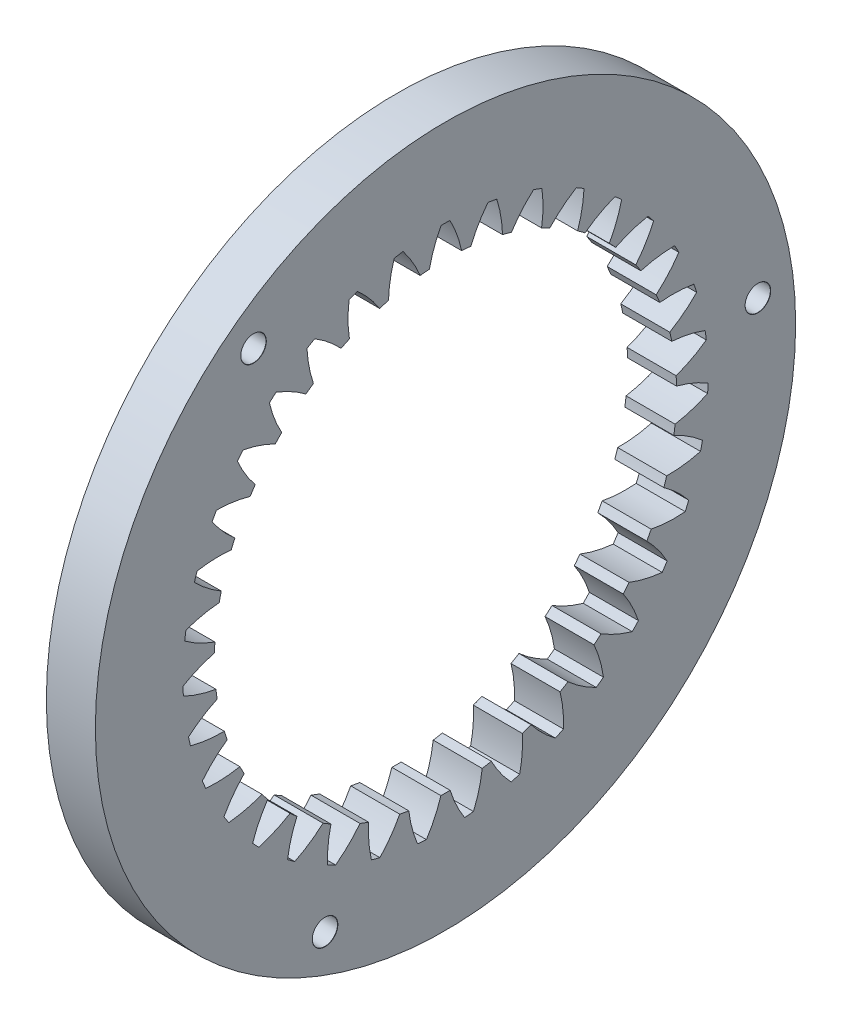
from build123d import *

# Parameters (mm, degrees)
SKETCH1_R                                    = 50
BOSS_EXTRUDE1_DEPTH                          = 7
CSK_FOR_M3_COUNTERSUNK_FLAT_HEAD_SCR_2_COUNT = 2
CSK_FOR_M3_COUNTERSUNK_FLAT_HEAD_SCR_2_PITCH = 77.942286341
CSK_FOR_M3_COUNTERSUNK_FLAT_HEAD_SCR_3_COUNT = 2
CSK_FOR_M3_COUNTERSUNK_FLAT_HEAD_SCR_3_PITCH = 77.942286341


with BuildPart() as part:
    # Sketch1 → Boss-Extrude1 (new body)
    with BuildSketch(Plane(origin=(-42.581895679, 0, 0), x_dir=(0, 0, -1), z_dir=(1, 0, 0))):
        with Locations((-27.777083352, -7.035052717)):
            Circle(SKETCH1_R)
        with BuildLine():
            ThreePointArc((-24.162682124, 25.766412247), (-23.082664784, 27.954818283), (-21.708715074, 29.971702172))
            ThreePointArc((-21.708715074, 29.971702172), (-21.08102124, 29.863290785), (-20.455259353, 29.744233496))
            ThreePointArc((-20.455259353, 29.744233496), (-19.877601945, 27.373185131), (-19.635402837, 24.944832186))
            ThreePointArc((-19.635402837, 24.944832186), (-18.997867448, 24.775721686), (-18.36383931, 24.59390295))
            ThreePointArc((-18.36383931, 24.59390295), (-16.910423307, 26.554295859), (-15.198425009, 28.2934394))
            ThreePointArc((-15.198425009, 28.2934394), (-14.600176074, 28.074691167), (-14.005728938, 27.845813078))
            ThreePointArc((-14.005728938, 27.845813078), (-13.860721755, 25.409723722), (-14.056014048, 22.977149088))
            ThreePointArc((-14.056014048, 22.977149088), (-13.458919961, 22.696919924), (-12.867545904, 22.404812994))
            ThreePointArc((-12.867545904, 22.404812994), (-11.087445224, 24.074184134), (-9.092423373, 25.479689823))
            ThreePointArc((-9.092423373, 25.479689823), (-8.54284755, 25.157635492), (-7.998821184, 24.826292933))
            ThreePointArc((-7.998821184, 24.826292933), (-8.291124878, 22.403460503), (-8.917631716, 20.044849129))
            ThreePointArc((-8.917631716, 20.044849129), (-8.380170026, 19.662508097), (-7.8504573, 19.269501531))
            ThreePointArc((-7.8504573, 19.269501531), (-5.800885844, 20.59419594), (-3.586962082, 21.620889668))
            ThreePointArc((-3.586962082, 21.620889668), (-3.10372319, 21.20588033), (-2.627603051, 20.782722924))
            ThreePointArc((-2.627603051, 20.782722924), (-3.347822739, 18.451019248), (-4.385407678, 16.242178844))
            ThreePointArc((-4.385407678, 16.242178844), (-3.924852846, 15.7700147), (-3.473826853, 15.288740051))
            ThreePointArc((-3.473826853, 15.288740051), (-1.220659533, 16.226180961), (1.141008807, 16.841063946))
            ThreePointArc((1.141008807, 16.841063946), (1.542379072, 16.346438343), (1.935290093, 15.845066716))
            ThreePointArc((1.935290093, 15.845066716), (0.810302863, 13.679434669), (-0.605011342, 11.691359184))
            ThreePointArc((-0.605011342, 11.691359184), (-0.236165979, 11.144547671), (0.121676933, 10.590473504))
            ThreePointArc((0.121676933, 10.590473504), (2.506021466, 11.110530792), (4.93952842, 11.293840189))
            ThreePointArc((4.93952842, 11.293840189), (5.246129688, 10.735495994), (5.543203106, 10.172024645))
            ThreePointArc((5.543203106, 10.172024645), (4.049606351, 8.242069422), (2.302052242, 6.538657238))
            ThreePointArc((2.302052242, 6.538657238), (2.567333142, 5.934773328), (2.820491609, 5.325708041))
            ThreePointArc((2.820491609, 5.325708041), (5.259378558, 5.411666639), (7.686509212, 5.157510734))
            ThreePointArc((7.686509212, 5.157510734), (7.888487066, 4.553393589), (8.080174697, 3.945932949))
            ThreePointArc((8.080174697, 3.945932949), (6.265973844, 2.313684899), (4.242347659, 0.949685085))
            ThreePointArc((4.242347659, 0.949685085), (4.39553775, 0.308138104), (4.53587505, -0.336342443))
            ThreePointArc((4.53587505, -0.336342443), (6.950916583, -0.687245316), (9.293660959, -1.370697744))
            ThreePointArc((9.293660959, -1.370697744), (9.384523664, -2.001171015), (9.464664511, -2.633096662))
            ThreePointArc((9.464664511, -2.633096662), (7.388169469, -3.915175743), (5.153512217, -4.895923111))
            ThreePointArc((5.153512217, -4.895923111), (5.189687844, -5.554513315), (5.21269342, -6.213694987))
            ThreePointArc((5.21269342, -6.213694987), (7.526268115, -6.990181023), (9.709328482, -8.08096325))
            ThreePointArc((9.709328482, -8.08096325), (9.686155637, -8.71752872), (9.652173906, -9.353608762))
            ThreePointArc((9.652173906, -9.353608762), (7.380124933, -10.244311798), (5.006260339, -10.810284693))
            ThreePointArc((5.006260339, -10.810284693), (4.924258786, -11.464750489), (4.829193221, -12.117446644))
            ThreePointArc((4.829193221, -12.117446644), (6.966940883, -13.294558944), (8.920151884, -14.757612332))
            ThreePointArc((8.920151884, -14.757612332), (8.783688283, -15.379810261), (8.636676176, -15.999600563))
            ThreePointArc((8.636676176, -15.999600563), (6.242098796, -16.470299625), (3.80532482, -16.603307212))
            ThreePointArc((3.80532482, -16.603307212), (3.607781686, -17.232613531), (3.397700465, -17.857845979))
            ThreePointArc((3.397700465, -17.857845979), (5.290912125, -19.397751184), (6.951495952, -21.186051993))
            ThreePointArc((6.951495952, -21.186051993), (6.706127647, -21.773884429), (6.450810253, -22.35746442))
            ThreePointArc((6.450810253, -22.35746442), (4.010668154, -22.393030854), (1.589304716, -22.088798159))
            ThreePointArc((1.589304716, -22.088798159), (1.282569199, -22.672718579), (0.964224506, -23.250391833))
            ThreePointArc((0.964224506, -23.250391833), (2.552050784, -25.103596123), (3.866634906, -27.159666895))
            ThreePointArc((3.866634906, -27.159666895), (3.520248236, -27.694240418), (3.164831666, -28.222853358))
            ThreePointArc((3.164831666, -28.222853358), (0.757553023, -27.822144028), (-1.570575263, -27.090449342))
            ThreePointArc((-1.570575263, -27.090449342), (-1.97664443, -27.610216178), (-2.393020737, -28.121763346))
            ThreePointArc((-2.393020737, -28.121763346), (-1.161613883, -30.22870321), (-0.235281281, -32.486460138))
            ThreePointArc((-0.235281281, -32.486460138), (-0.671553163, -32.950593117), (-1.115645527, -33.40724895))
            ThreePointArc((-1.115645527, -33.40724895), (-3.412688799, -32.583142985), (-5.572753975, -31.447503575))
            ThreePointArc((-5.572753975, -31.447503575), (-6.065105396, -31.886411095), (-6.566130637, -32.315390629))
            ThreePointArc((-6.566130637, -32.315390629), (-5.730721638, -34.608347287), (-5.222413648, -36.995224204))
            ThreePointArc((-5.222413648, -36.995224204), (-5.734548606, -37.373999023), (-6.25304327, -37.744020455))
            ThreePointArc((-6.25304327, -37.744020455), (-8.366022309, -36.523005299), (-10.288598102, -35.019921551))
            ThreePointArc((-10.288598102, -35.019921551), (-10.851407197, -35.363862906), (-11.420978011, -35.696487051))
            ThreePointArc((-11.420978011, -35.696487051), (-11.008417598, -38.101762989), (-10.934471658, -40.541043708))
            ThreePointArc((-10.934471658, -40.541043708), (-11.506009251, -40.822286232), (-12.082241371, -41.093780471))
            ThreePointArc((-12.082241371, -41.093780471), (-13.943243293, -39.515100554), (-15.566536535, -37.692882817))
            ThreePointArc((-15.566536535, -37.692882817), (-16.181714157, -37.930803448), (-16.801524067, -38.15638139))
            ThreePointArc((-16.801524067, -38.15638139), (-16.825072273, -40.596669061), (-17.187865066, -43.009953093))
            ThreePointArc((-17.187865066, -43.009953093), (-17.800435606, -43.184623956), (-18.415884607, -43.348864952))
            ThreePointArc((-18.415884607, -43.348864952), (-19.965095278, -41.463260347), (-21.23693199, -39.380476198))
            ThreePointArc((-21.23693199, -39.380476198), (-21.884705823, -39.504729141), (-22.53483363, -39.61601062))
            ThreePointArc((-22.53483363, -39.61601062), (-22.993733596, -42.012877169), (-23.781604662, -44.32259958))
            ThreePointArc((-23.781604662, -44.32259958), (-24.415519629, -44.385084716), (-25.050404473, -44.43679363))
            ThreePointArc((-25.050404473, -44.43679363), (-26.238030988, -42.304869219), (-27.117533291, -40.028461054))
            ThreePointArc((-27.117533291, -40.028461054), (-27.777083352, -40.035052717), (-28.436633413, -40.028461054))
            ThreePointArc((-28.436633413, -40.028461054), (-29.316135715, -42.304869219), (-30.50376223, -44.43679363))
            ThreePointArc((-30.50376223, -44.43679363), (-31.138647075, -44.385084716), (-31.772562042, -44.32259958))
            ThreePointArc((-31.772562042, -44.32259958), (-32.560433108, -42.012877169), (-33.019333073, -39.61601062))
            ThreePointArc((-33.019333073, -39.61601062), (-33.66946088, -39.504729141), (-34.317234714, -39.380476198))
            ThreePointArc((-34.317234714, -39.380476198), (-35.589071425, -41.463260347), (-37.138282096, -43.348864952))
            ThreePointArc((-37.138282096, -43.348864952), (-37.753731097, -43.184623956), (-38.366301638, -43.009953093))
            ThreePointArc((-38.366301638, -43.009953093), (-38.72909443, -40.596669061), (-38.752642636, -38.15638139))
            ThreePointArc((-38.752642636, -38.15638139), (-39.372452547, -37.930803448), (-39.987630168, -37.692882817))
            ThreePointArc((-39.987630168, -37.692882817), (-41.610923411, -39.515100554), (-43.471925333, -41.093780471))
            ThreePointArc((-43.471925333, -41.093780471), (-44.048157452, -40.822286232), (-44.619695046, -40.541043708))
            ThreePointArc((-44.619695046, -40.541043708), (-44.545749105, -38.101762989), (-44.133188693, -35.696487051))
            ThreePointArc((-44.133188693, -35.696487051), (-44.702759506, -35.363862906), (-45.265568601, -35.019921551))
            ThreePointArc((-45.265568601, -35.019921551), (-47.188144395, -36.523005299), (-49.301123433, -37.744020455))
            ThreePointArc((-49.301123433, -37.744020455), (-49.819618098, -37.373999023), (-50.331753055, -36.995224204))
            ThreePointArc((-50.331753055, -36.995224204), (-49.823445066, -34.608347287), (-48.988036066, -32.315390629))
            ThreePointArc((-48.988036066, -32.315390629), (-49.489061308, -31.886411095), (-49.981412729, -31.447503575))
            ThreePointArc((-49.981412729, -31.447503575), (-52.141477905, -32.583142985), (-54.438521176, -33.40724895))
            ThreePointArc((-54.438521176, -33.40724895), (-54.88261354, -32.950593117), (-55.318885423, -32.486460138))
            ThreePointArc((-55.318885423, -32.486460138), (-54.392552821, -30.22870321), (-53.161145967, -28.121763346))
            ThreePointArc((-53.161145967, -28.121763346), (-53.577522273, -27.610216178), (-53.983591441, -27.090449342))
            ThreePointArc((-53.983591441, -27.090449342), (-56.311719727, -27.822144028), (-58.71899837, -28.222853358))
            ThreePointArc((-58.71899837, -28.222853358), (-59.07441494, -27.694240418), (-59.42080161, -27.159666895))
            ThreePointArc((-59.42080161, -27.159666895), (-58.106217488, -25.103596123), (-56.518391209, -23.250391833))
            ThreePointArc((-56.518391209, -23.250391833), (-56.836735903, -22.672718579), (-57.14347142, -22.088798159))
            ThreePointArc((-57.14347142, -22.088798159), (-59.564834858, -22.393030854), (-62.004976956, -22.35746442))
            ThreePointArc((-62.004976956, -22.35746442), (-62.26029435, -21.773884429), (-62.505662656, -21.186051993))
            ThreePointArc((-62.505662656, -21.186051993), (-60.845078829, -19.397751184), (-58.951867168, -17.857845979))
            ThreePointArc((-58.951867168, -17.857845979), (-59.16194839, -17.232613531), (-59.359491523, -16.603307212))
            ThreePointArc((-59.359491523, -16.603307212), (-61.7962655, -16.470299625), (-64.190842879, -15.999600563))
            ThreePointArc((-64.190842879, -15.999600563), (-64.337854987, -15.379810261), (-64.474318588, -14.757612332))
            ThreePointArc((-64.474318588, -14.757612332), (-62.521107587, -13.294558944), (-60.383359925, -12.117446644))
            ThreePointArc((-60.383359925, -12.117446644), (-60.47842549, -11.464750489), (-60.560427042, -10.810284693))
            ThreePointArc((-60.560427042, -10.810284693), (-62.934291637, -10.244311798), (-65.20634061, -9.353608762))
            ThreePointArc((-65.20634061, -9.353608762), (-65.24032234, -8.71752872), (-65.263495185, -8.08096325))
            ThreePointArc((-65.263495185, -8.08096325), (-63.080434819, -6.990181023), (-60.766860124, -6.213694987))
            ThreePointArc((-60.766860124, -6.213694987), (-60.743854548, -5.554513315), (-60.707678921, -4.895923111))
            ThreePointArc((-60.707678921, -4.895923111), (-62.942336172, -3.915175743), (-65.018831215, -2.633096662))
            ThreePointArc((-65.018831215, -2.633096662), (-64.938690368, -2.001171015), (-64.847827662, -1.370697744))
            ThreePointArc((-64.847827662, -1.370697744), (-62.505083287, -0.687245316), (-60.090041754, -0.336342443))
            ThreePointArc((-60.090041754, -0.336342443), (-59.949704454, 0.308138104), (-59.796514362, 0.949685085))
            ThreePointArc((-59.796514362, 0.949685085), (-61.820140548, 2.313684899), (-63.634341401, 3.945932949))
            ThreePointArc((-63.634341401, 3.945932949), (-63.442653769, 4.553393589), (-63.240675915, 5.157510734))
            ThreePointArc((-63.240675915, 5.157510734), (-60.813545262, 5.411666639), (-58.374658313, 5.325708041))
            ThreePointArc((-58.374658313, 5.325708041), (-58.121499846, 5.934773328), (-57.856218946, 6.538657238))
            ThreePointArc((-57.856218946, 6.538657238), (-59.603773054, 8.242069422), (-61.09736981, 10.172024645))
            ThreePointArc((-61.09736981, 10.172024645), (-60.800296392, 10.735495994), (-60.493695124, 11.293840189))
            ThreePointArc((-60.493695124, 11.293840189), (-58.060188169, 11.110530792), (-55.675843637, 10.590473504))
            ThreePointArc((-55.675843637, 10.590473504), (-55.318000725, 11.144547671), (-54.949155362, 11.691359184))
            ThreePointArc((-54.949155362, 11.691359184), (-56.364469567, 13.679434669), (-57.489456797, 15.845066716))
            ThreePointArc((-57.489456797, 15.845066716), (-57.096545776, 16.346438343), (-56.69517551, 16.841063946))
            ThreePointArc((-56.69517551, 16.841063946), (-54.333507171, 16.226180961), (-52.080339851, 15.288740051))
            ThreePointArc((-52.080339851, 15.288740051), (-51.629313858, 15.7700147), (-51.168759026, 16.242178844))
            ThreePointArc((-51.168759026, 16.242178844), (-52.206343964, 18.451019248), (-52.926563653, 20.782722924))
            ThreePointArc((-52.926563653, 20.782722924), (-52.450443513, 21.20588033), (-51.967204621, 21.620889668))
            ThreePointArc((-51.967204621, 21.620889668), (-49.75328086, 20.59419594), (-47.703709403, 19.269501531))
            ThreePointArc((-47.703709403, 19.269501531), (-47.173996678, 19.662508097), (-46.636534987, 20.044849129))
            ThreePointArc((-46.636534987, 20.044849129), (-47.263041826, 22.403460503), (-47.555345519, 24.826292933))
            ThreePointArc((-47.555345519, 24.826292933), (-47.011319154, 25.157635492), (-46.461743331, 25.479689823))
            ThreePointArc((-46.461743331, 25.479689823), (-44.466721479, 24.074184134), (-42.686620799, 22.404812994))
            ThreePointArc((-42.686620799, 22.404812994), (-42.095246743, 22.696919924), (-41.498152656, 22.977149088))
            ThreePointArc((-41.498152656, 22.977149088), (-41.693444948, 25.409723722), (-41.548437766, 27.845813078))
            ThreePointArc((-41.548437766, 27.845813078), (-40.95399063, 28.074691167), (-40.355741695, 28.2934394))
            ThreePointArc((-40.355741695, 28.2934394), (-38.643743397, 26.554295859), (-37.190327394, 24.59390295))
            ThreePointArc((-37.190327394, 24.59390295), (-36.556299256, 24.775721686), (-35.918763867, 24.944832186))
            ThreePointArc((-35.918763867, 24.944832186), (-35.676564759, 27.373185131), (-35.098907351, 29.744233496))
            ThreePointArc((-35.098907351, 29.744233496), (-34.473145464, 29.863290785), (-33.84545163, 29.971702172))
            ThreePointArc((-33.84545163, 29.971702172), (-32.471501919, 27.954818283), (-31.39148458, 25.766412247))
            ThreePointArc((-31.39148458, 25.766412247), (-30.735180546, 25.832098985), (-30.077694767, 25.88465547))
            ThreePointArc((-30.077694767, 25.88465547), (-29.405788737, 28.230737463), (-28.414047488, 30.460537393))
            ThreePointArc((-28.414047488, 30.460537393), (-27.777083352, 30.465947283), (-27.140119216, 30.460537393))
            ThreePointArc((-27.140119216, 30.460537393), (-26.148377967, 28.230737463), (-25.476471936, 25.88465547))
            ThreePointArc((-25.476471936, 25.88465547), (-24.818986158, 25.832098985), (-24.162682124, 25.766412247))
        make_face(mode=Mode.SUBTRACT)
    extrude(amount=-BOSS_EXTRUDE1_DEPTH)

    # Sketch3 → CSK for M3 Countersunk Flat Head Screw1 (revolve, cut)
    with BuildSketch(Plane(origin=(-49.581895679, -1.137692649, -16.834811298), x_dir=(0, 0, 1), z_dir=(0, 1, 0))):
        Polygon((0, 0), (0, 7), (1.825, 7), (1.8, 6.975), (1.8, 1.35), (3.15, 0), align=None)
    csk_for_m3_countersunk_flat_head_screw1 = revolve(axis=Axis((-55.931895679, -1.137692649, -16.834811298), (1, 0, 0)), mode=Mode.SUBTRACT)

    # CSK for M3 Countersunk Flat Head Scr 2: CSK for M3 Countersunk Flat Head Screw1 ×2
    with Locations(*[Vector(0, 0.382192971, 0.924082536) * (i * CSK_FOR_M3_COUNTERSUNK_FLAT_HEAD_SCR_2_PITCH) for i in range(1, CSK_FOR_M3_COUNTERSUNK_FLAT_HEAD_SCR_2_COUNT)]):
        add(csk_for_m3_countersunk_flat_head_screw1, mode=Mode.SUBTRACT)

    # CSK for M3 Countersunk Flat Head Scr 3: CSK for M3 Countersunk Flat Head Screw1 ×2
    with Locations(*[Vector(0, -0.609182466, 0.79303009) * (i * CSK_FOR_M3_COUNTERSUNK_FLAT_HEAD_SCR_3_PITCH) for i in range(1, CSK_FOR_M3_COUNTERSUNK_FLAT_HEAD_SCR_3_COUNT)]):
        add(csk_for_m3_countersunk_flat_head_screw1, mode=Mode.SUBTRACT)


solid = part.part
